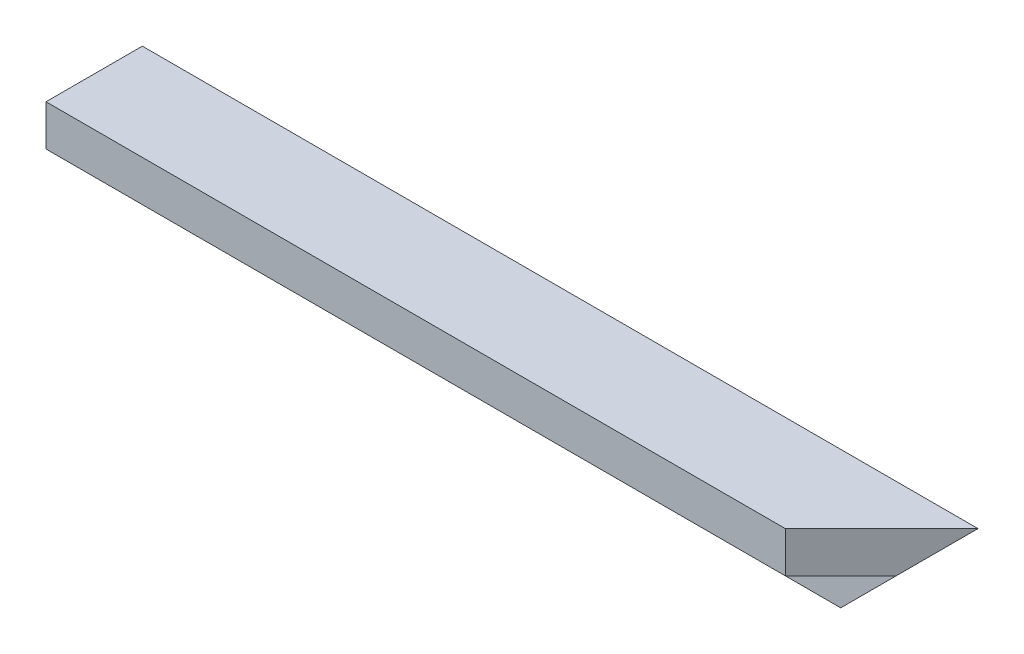
from build123d import *

# Parameters (mm, degrees)
BOSS_EXTRU_1_START      = -125
BOSS_EXTRU_1_DEPTH      = 347
ENL_V_MAT_EXTRU_1_DEPTH = 41
ENL_V_MAT_EXTRU_2_DEPTH = 41


with BuildPart() as part:
    # Esquisse1 → Boss.-Extru.1 (new body)
    with BuildSketch(Plane(origin=(0, 0, 0), x_dir=(0, 0, -1), z_dir=(1, 0, 0)).offset(BOSS_EXTRU_1_START)):
        Polygon((0, 0), (-40, 0), (-40, -17), (-17, -17), (-17, -40), (0, -40), align=None)
    extrude(amount=BOSS_EXTRU_1_DEPTH)

    # Esquisse2 → Enlèv. mat.-Extru.1 (cut, through all)
    with BuildSketch(Plane(origin=(0, 0, 0), x_dir=(1, 0, 0), z_dir=(0, 1, 0))):
        Polygon((222, 0), (182, -40), (222, -40), align=None)
    extrude(amount=-ENL_V_MAT_EXTRU_1_DEPTH, mode=Mode.SUBTRACT)

    # Esquisse3 → Enlèv. mat.-Extru.2 (cut, through all)
    with BuildSketch(Plane(origin=(0, 0, 0), x_dir=(-1, 0, 0), z_dir=(0, 0, -1))):
        Polygon((-222, 0), (-182, -40), (-222, -40), align=None)
    extrude(amount=-ENL_V_MAT_EXTRU_2_DEPTH, mode=Mode.SUBTRACT)


solid = part.part
